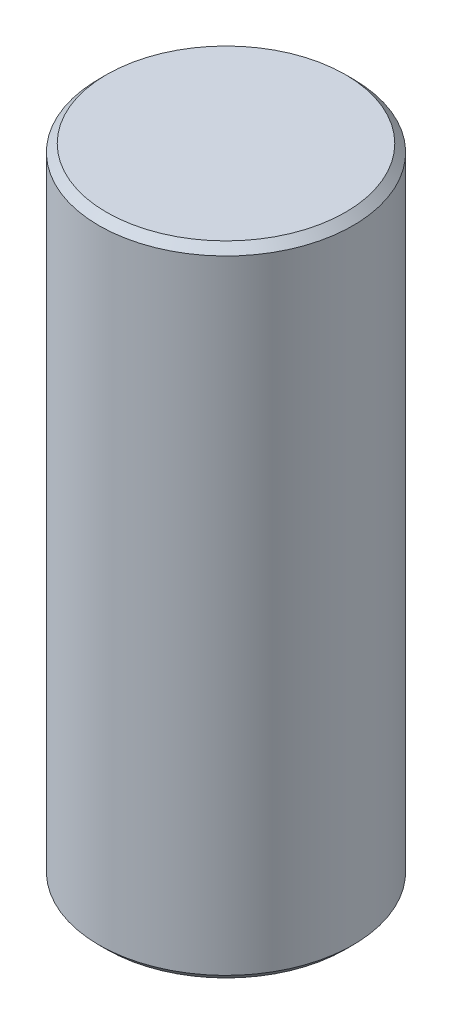
from build123d import *


with BuildPart() as part:
    # Sketch1 → Revolve1 (revolve)
    with BuildSketch(Plane.XY, mode=Mode.PRIVATE) as revolve1_sk:
        Polygon((12.6365, 0.762), (12.6365, 62.738), (11.8745, 63.5), (0, 63.5), (0, 4.826), (6.1214, 4.826), (6.3754, 4.572), (6.3754, 0), (11.8745, 0), align=None)
    revolve(revolve1_sk.sketch.rotate(Axis((0, 0, 0), (0, 1, 0)), 90), axis=Axis((0, 0, 0), (0, 1, 0)))  # turned: the seam where the file's is


solid = part.part
